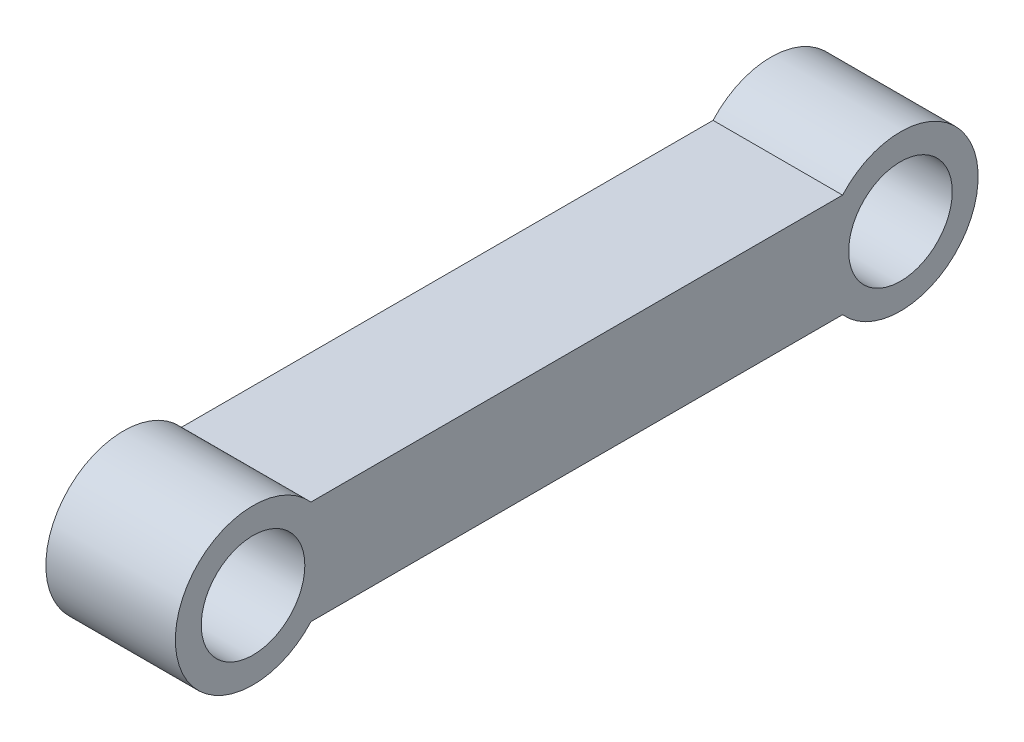
from build123d import *

# Parameters (mm, degrees)
LINKFRAME_R         = 40
BOSS_EXTRUDE1_DEPTH = 100


with BuildPart() as part:
    # LinkFrame → Boss-Extrude1 (new body)
    with BuildSketch(Plane(origin=(0, 0, 0), x_dir=(0, 0, -1), z_dir=(1, 0, 0))):
        with BuildLine():
            Line((-195.62417903, -186.263273145), (214.93310187, -186.263273145))
            ThreePointArc((214.93310187, -186.263273145), (319.65446142, -226.263273145), (214.93310187, -266.263273145))
            Line((214.93310187, -266.263273145), (-195.62417903, -266.263273145))
            ThreePointArc((-195.62417903, -266.263273145), (-300.34553858, -226.263273145), (-195.62417903, -186.263273145))
        make_face()
        with Locations((-240.34553858, -226.263273145)):
            Circle(LINKFRAME_R, mode=Mode.SUBTRACT)
        with Locations((259.65446142, -226.263273145)):
            Circle(LINKFRAME_R, mode=Mode.SUBTRACT)
    extrude(amount=BOSS_EXTRUDE1_DEPTH)


solid = part.part
